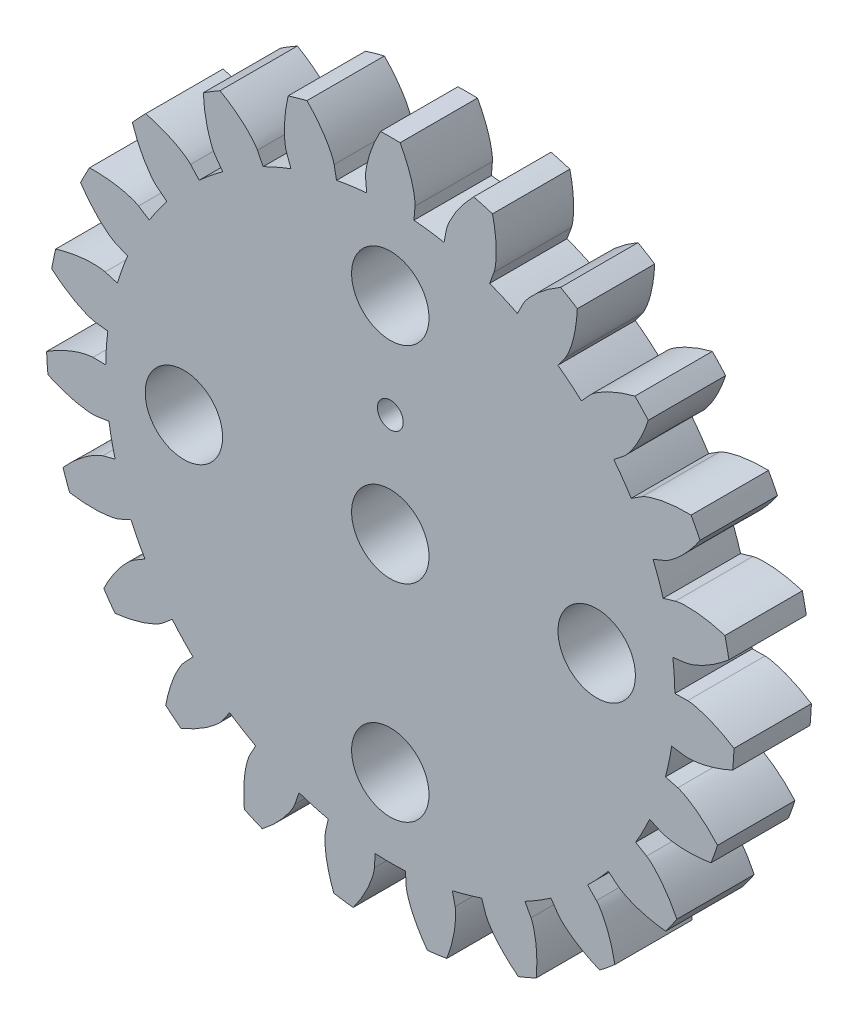
from build123d import *

# Parameters (mm, degrees)
BOSS_EXTRUDE1_DEPTH = 3
SKETCH2_R           = 1.5
SKETCH2_R_2         = 0.5
CUT_EXTRUDE1_DEPTH  = 4.0000001


with BuildPart() as part:
    # Model → Boss-Extrude1 (new body)
    with BuildSketch(Plane.XY):
        with BuildLine():
            Line((-3.538746102, -10.448013917), (-3.69731571, -10.916184682))
            add(Edge.make_bspline(
                [(-3.69731571, -10.916184682), (-3.706904602, -10.940308677), (-3.747498158, -11.035961617), (-3.865200891, -11.238603118), (-4.093466254, -11.554754655), (-4.463378416, -11.956665333), (-4.776092769, -12.231743922), (-4.961450629, -12.373903165)],
                knots=[34.58462916, 34.58462916, 34.58462916, 34.58462916, 34.662508722, 34.896108405, 35.285436008, 35.830492648, 36.531278694, 36.531278694, 36.531278694, 36.531278694], degree=3))
            ThreePointArc((-4.961450629, -12.373903165), (-5.31129279, -12.227822405), (-5.656839729, -12.071853054))
            add(Edge.make_bspline(
                [(-5.656839729, -12.071853054), (-5.679461232, -11.839355625), (-5.691868071, -11.423056974), (-5.650622002, -10.878386466), (-5.57537033, -10.495771704), (-5.507611003, -10.271436721), (-5.465411654, -10.176481275), (-5.454325899, -10.153007459)],
                knots=[37.289536731, 37.289536731, 37.289536731, 37.289536731, 37.990322777, 38.535379417, 38.92470702, 39.158306703, 39.236186265, 39.236186265, 39.236186265, 39.236186265], degree=3))
            Line((-5.454325899, -10.153007459), (-5.220402051, -9.717567659))
            ThreePointArc((-5.220402051, -9.717567659), (-5.731548399, -9.425129799), (-6.226360217, -9.105830947))
            Line((-6.226360217, -9.105830947), (-6.505360594, -9.513859102))
            add(Edge.make_bspline(
                [(-6.505360594, -9.513859102), (-6.521102481, -9.534501462), (-6.585997572, -9.615655321), (-6.75400759, -9.779026508), (-7.059104919, -10.02186903), (-7.523733938, -10.309074663), (-7.899067309, -10.489583269), (-8.115905702, -10.576461909)],
                knots=[41.402695863, 41.402695863, 41.402695863, 41.402695863, 41.480575425, 41.714175107, 42.103502711, 42.64855935, 43.349345397, 43.349345397, 43.349345397, 43.349345397], degree=3))
            ThreePointArc((-8.115905702, -10.576461909), (-8.413362649, -10.341411935), (-8.704015743, -10.097998902))
            add(Edge.make_bspline(
                [(-8.704015743, -10.097998902), (-8.663071323, -9.8680199), (-8.562702051, -9.463811408), (-8.376035154, -8.950466815), (-8.200345791, -8.602343105), (-8.074574309, -8.404608319), (-8.008321154, -8.324559327), (-7.991313329, -8.304946884)],
                knots=[44.107603434, 44.107603434, 44.107603434, 44.107603434, 44.80838948, 45.35344612, 45.742773723, 45.976373406, 46.054252968, 46.054252968, 46.054252968, 46.054252968], degree=3))
            Line((-7.991313329, -8.304946884), (-7.64858376, -7.948766272))
            ThreePointArc((-7.64858376, -7.948766272), (-8.061876625, -7.529267167), (-8.452193678, -7.088310152))
            Line((-8.452193678, -7.088310152), (-8.830932644, -7.405934115))
            add(Edge.make_bspline(
                [(-8.830932644, -7.405934115), (-8.85166002, -7.42156389), (-8.936043675, -7.482199858), (-9.141900445, -7.594184238), (-9.501202065, -7.745707227), (-10.026088532, -7.896907086), (-10.436204162, -7.969458212), (-10.668441176, -7.994612858)],
                knots=[48.220762566, 48.220762566, 48.220762566, 48.220762566, 48.298642127, 48.53224181, 48.921569414, 49.466626053, 50.167412099, 50.167412099, 50.167412099, 50.167412099], degree=3))
            ThreePointArc((-10.668441176, -7.994612858), (-10.891451889, -7.688026251), (-11.105654727, -7.375222367))
            add(Edge.make_bspline(
                [(-11.105654727, -7.375222367), (-11.004181046, -7.164818282), (-10.798479592, -6.802678243), (-10.480236096, -6.358731987), (-10.217139118, -6.070918071), (-10.042683378, -5.914448566), (-9.957290109, -5.855242896), (-9.935621607, -5.840946392)],
                knots=[50.925670137, 50.925670137, 50.925670137, 50.925670137, 51.626456183, 52.171512822, 52.560840426, 52.794440109, 52.872319671, 52.872319671, 52.872319671, 52.872319671], degree=3))
            Line((-9.935621607, -5.840946392), (-9.509505001, -5.590441255))
            ThreePointArc((-9.509505001, -5.590441255), (-9.794292341, -5.074993233), (-10.051166601, -4.54508182))
            Line((-10.051166601, -4.54508182), (-10.501554817, -4.748744875))
            add(Edge.make_bspline(
                [(-10.501554817, -4.748744875), (-10.52573043, -4.758202876), (-10.623344298, -4.79382386), (-10.851780364, -4.846116064), (-11.238638519, -4.895081752), (-11.784854006, -4.899062036), (-12.199335495, -4.858274897), (-12.429747173, -4.819839944)],
                knots=[55.038829268, 55.038829268, 55.038829268, 55.038829268, 55.11670883, 55.350308513, 55.739636117, 56.284692756, 56.985478802, 56.985478802, 56.985478802, 56.985478802], degree=3))
            ThreePointArc((-12.429747173, -4.819839944), (-12.561771967, -4.46445483), (-12.683638105, -4.105459328))
            add(Edge.make_bspline(
                [(-12.683638105, -4.105459328), (-12.529161, -3.930234869), (-12.233383301, -3.637021553), (-11.807165871, -3.295399096), (-11.476173977, -3.089240816), (-11.265972562, -2.98564122), (-11.167772409, -2.951669885), (-11.143050283, -2.943749626)],
                knots=[57.74373684, 57.74373684, 57.74373684, 57.74373684, 58.444522886, 58.989579525, 59.378907129, 59.612506812, 59.690386373, 59.690386373, 59.690386373, 59.690386373], degree=3))
            Line((-11.143050283, -2.943749626), (-10.665149759, -2.817498783))
            ThreePointArc((-10.665149759, -2.817498783), (-10.800310201, -2.244330268), (-10.904690477, -1.664765561))
            Line((-10.904690477, -1.664765561), (-11.393324712, -1.739362951))
            add(Edge.make_bspline(
                [(-11.393324712, -1.739362951), (-11.419155565, -1.741947722), (-11.522760073, -1.749911877), (-11.756833378, -1.738633631), (-12.142556567, -1.681410458), (-12.66959077, -1.537875967), (-13.057697923, -1.386775558), (-13.269195685, -1.287601551)],
                knots=[61.856895971, 61.856895971, 61.856895971, 61.856895971, 61.934775533, 62.168375216, 62.557702819, 63.102759459, 63.803545505, 63.803545505, 63.803545505, 63.803545505], degree=3))
            ThreePointArc((-13.269195685, -1.287601551), (-13.300442885, -0.909775217), (-13.320934069, -0.531213152))
            add(Edge.make_bspline(
                [(-13.320934069, -0.531213152), (-13.124910401, -0.404163916), (-12.760992935, -0.201623613), (-12.258412168, 0.012338471), (-11.884073513, 0.121551298), (-11.6537161, 0.164597476), (-11.549992118, 0.170814978), (-11.524049895, 0.171771583)],
                knots=[64.561803542, 64.561803542, 64.561803542, 64.561803542, 65.262589589, 65.807646228, 66.196973832, 66.430573514, 66.508453076, 66.508453076, 66.508453076, 66.508453076], degree=3))
            Line((-11.524049895, 0.171771583), (-11.02980915, 0.164404683))
            ThreePointArc((-11.02980915, 0.164404683), (-11.005318461, 0.752784406), (-10.949463347, 1.339018743))
            Line((-10.949463347, 1.339018743), (-11.440103834, 1.399019565))
            add(Edge.make_bspline(
                [(-11.440103834, 1.399019565), (-11.465674172, 1.403499726), (-11.567585446, 1.423783064), (-11.789935844, 1.497795305), (-12.145916744, 1.656963359), (-12.614681946, 1.937367327), (-12.947630631, 2.18757458), (-13.124528655, 2.340132359)],
                knots=[68.674962674, 68.674962674, 68.674962674, 68.674962674, 68.752842236, 68.986441919, 69.375769522, 69.920826162, 70.621612208, 70.621612208, 70.621612208, 70.621612208], degree=3))
            ThreePointArc((-13.124528655, 2.340132359), (-13.052680799, 2.712378261), (-12.970277292, 3.082430673))
            add(Edge.make_bspline(
                [(-12.970277292, 3.082430673), (-12.747245239, 3.151882026), (-12.342178101, 3.248727828), (-11.800508112, 3.319160949), (-11.410585682, 3.323328508), (-11.177156827, 3.302628731), (-11.07560175, 3.280631276), (-11.050363446, 3.274553279)],
                knots=[71.379870245, 71.379870245, 71.379870245, 71.379870245, 72.080656291, 72.625712931, 73.015040534, 73.248640217, 73.326519779, 73.326519779, 73.326519779, 73.326519779], degree=3))
            Line((-11.050363446, 3.274553279), (-10.576438054, 3.134115007))
            ThreePointArc((-10.576438054, 3.134115007), (-10.394112597, 3.694068504), (-10.182164611, 4.243494152))
            Line((-10.182164611, 4.243494152), (-10.638422789, 4.433643201))
            add(Edge.make_bspline(
                [(-10.638422789, 4.433643201), (-10.661836177, 4.444856019), (-10.754495925, 4.49188253), (-10.948632704, 4.623139615), (-11.248469839, 4.872447783), (-11.624199871, 5.268924949), (-11.877296806, 5.599682319), (-12.006475376, 5.794309358)],
                knots=[75.493029377, 75.493029377, 75.493029377, 75.493029377, 75.570908939, 75.804508621, 76.193836225, 76.738892864, 77.439678911, 77.439678911, 77.439678911, 77.439678911], degree=3))
            ThreePointArc((-12.006475376, 5.794309358), (-11.836861091, 6.133367052), (-11.657674383, 6.467464716))
            add(Edge.make_bspline(
                [(-11.657674383, 6.467464716), (-11.424175213, 6.474167298), (-11.008000378, 6.458135988), (-10.467414354, 6.379816444), (-10.090826911, 6.278629646), (-9.871638964, 6.195719121), (-9.779784667, 6.147138159), (-9.757122092, 6.134476338)],
                knots=[78.197936948, 78.197936948, 78.197936948, 78.197936948, 78.898722994, 79.443779633, 79.833107237, 80.06670692, 80.144586482, 80.144586482, 80.144586482, 80.144586482], degree=3))
            Line((-9.757122092, 6.134476338), (-9.338660931, 5.871382358))
            ThreePointArc((-9.338660931, 5.871382358), (-9.012022951, 6.361380441), (-8.659701306, 6.833249014))
            Line((-8.659701306, 6.833249014), (-9.047738594, 7.139443803))
            add(Edge.make_bspline(
                [(-9.047738594, 7.139443803), (-9.067258567, 7.156557676), (-9.14379464, 7.226839617), (-9.295319562, 7.405606809), (-9.516775385, 7.726565045), (-9.771604069, 8.209710512), (-9.926078213, 8.596487237), (-9.997956744, 8.818748938)],
                knots=[82.31109608, 82.31109608, 82.31109608, 82.31109608, 82.388975641, 82.622575324, 83.011902928, 83.556959567, 84.257745613, 84.257745613, 84.257745613, 84.257745613], degree=3))
            ThreePointArc((-9.997956744, 8.818748938), (-9.743155546, 9.099472067), (-9.480475096, 9.372836489))
            add(Edge.make_bspline(
                [(-9.480475096, 9.372836489), (-9.253826374, 9.316293198), (-8.857409626, 9.188573746), (-8.358000358, 8.967310139), (-8.02267767, 8.768273546), (-7.833986799, 8.629301368), (-7.758645695, 8.557739927), (-7.740239628, 8.539433351)],
                knots=[85.016003651, 85.016003651, 85.016003651, 85.016003651, 85.716789697, 86.261846336, 86.65117394, 86.884773623, 86.962653185, 86.962653185, 86.962653185, 86.962653185], degree=3))
            Line((-7.740239628, 8.539433351), (-7.408278049, 8.173196139))
            ThreePointArc((-7.408278049, 8.173196139), (-6.96155279, 8.556897892), (-6.49498757, 8.916213055))
            Line((-6.49498757, 8.916213055), (-6.786025017, 9.315744518))
            add(Edge.make_bspline(
                [(-6.786025017, 9.315744518), (-6.800203869, 9.337490189), (-6.854939937, 9.42581507), (-6.952615092, 9.638834025), (-7.079265237, 10.007638324), (-7.194293095, 10.541619403), (-7.238687807, 10.955730023), (-7.247935398, 11.189142253)],
                knots=[89.129162782, 89.129162782, 89.129162782, 89.129162782, 89.207042344, 89.440642027, 89.829969631, 90.37502627, 91.075812316, 91.075812316, 91.075812316, 91.075812316], degree=3))
            ThreePointArc((-7.247935398, 11.189142253), (-6.926844725, 11.390710866), (-6.600152341, 11.583067856))
            add(Edge.make_bspline(
                [(-6.600152341, 11.583067856), (-6.397163565, 11.467472251), (-6.049905322, 11.237537024), (-5.628711711, 10.889739464), (-5.359523128, 10.607614709), (-5.215323671, 10.422887809), (-5.162083466, 10.333653274), (-5.149299001, 10.311059658)],
                knots=[91.834070354, 91.834070354, 91.834070354, 91.834070354, 92.5348564, 93.079913039, 93.469240643, 93.702840326, 93.780719887, 93.780719887, 93.780719887, 93.780719887], degree=3))
            Line((-5.149299001, 10.311059658), (-4.928457074, 9.868841353))
            ThreePointArc((-4.928457074, 9.868841353), (-4.394776106, 10.117789371), (-3.848570319, 10.337902364))
            Line((-3.848570319, 10.337902364), (-4.02102301, 10.80113908))
            add(Edge.make_bspline(
                [(-4.02102301, 10.80113908), (-4.02880916, 10.82590377), (-4.057685698, 10.925720939), (-4.094266967, 11.157193015), (-4.116718371, 11.546490851), (-4.083414314, 12.091704607), (-4.014437041, 12.502436432), (-3.96036784, 12.729688074)],
                knots=[95.947229485, 95.947229485, 95.947229485, 95.947229485, 96.025109047, 96.25870873, 96.648036333, 97.193092973, 97.893879019, 97.893879019, 97.893879019, 97.893879019], degree=3))
            ThreePointArc((-3.96036784, 12.729688074), (-3.59680152, 12.837152749), (-3.23032648, 12.93423607))
            add(Edge.make_bspline(
                [(-3.23032648, 12.93423607), (-3.066052401, 12.768161347), (-2.793707216, 12.453063589), (-2.481967266, 12.00452663), (-2.298877274, 11.660237616), (-2.209863845, 11.443456342), (-2.18267312, 11.34316683), (-2.176458423, 11.31796184)],
                knots=[98.652137056, 98.652137056, 98.652137056, 98.652137056, 99.352923103, 99.897979742, 100.287307346, 100.520907028, 100.59878659, 100.59878659, 100.59878659, 100.59878659], degree=3))
            Line((-2.176458423, 11.31796184), (-2.083114985, 10.83255975))
            ThreePointArc((-2.083114985, 10.83255975), (-1.502058983, 10.928290699), (-0.916722213, 10.992876747))
            Line((-0.916722213, 10.992876747), (-0.95780012, 11.485462568))
            add(Edge.make_bspline(
                [(-0.95780012, 11.485462568), (-0.958616105, 11.511409594), (-0.959491473, 11.615316069), (-0.932265791, 11.848074041), (-0.848853337, 12.228992973), (-0.669687373, 12.745003397), (-0.492453845, 13.121894326), (-0.379077917, 13.326131165)],
                knots=[102.765296188, 102.765296188, 102.765296188, 102.765296188, 102.84317575, 103.076775433, 103.466103036, 104.011159676, 104.711945722, 104.711945722, 104.711945722, 104.711945722], degree=3))
            ThreePointArc((-0.379077917, 13.326131165), (0, 13.331521739), (0.379077917, 13.326131165))
            add(Edge.make_bspline(
                [(0.379077917, 13.326131165), (0.492453845, 13.121894326), (0.669687373, 12.745003397), (0.848853337, 12.228992973), (0.932265791, 11.848074041), (0.959491473, 11.615316069), (0.958616105, 11.511409594), (0.95780012, 11.485462568)],
                knots=[105.470203759, 105.470203759, 105.470203759, 105.470203759, 106.170989805, 106.716046445, 107.105374048, 107.338973731, 107.416853293, 107.416853293, 107.416853293, 107.416853293], degree=3))
            Line((0.95780012, 11.485462568), (0.916722213, 10.992876747))
            ThreePointArc((0.916722213, 10.992876747), (1.502058983, 10.928290699), (2.083114985, 10.83255975))
            Line((2.083114985, 10.83255975), (2.176458423, 11.31796184))
            add(Edge.make_bspline(
                [(2.176458423, 11.31796184), (2.18267312, 11.34316683), (2.209863845, 11.443456342), (2.298877274, 11.660237616), (2.481967266, 12.00452663), (2.793707216, 12.453063589), (3.066052401, 12.768161347), (3.23032648, 12.93423607)],
                knots=[109.583362891, 109.583362891, 109.583362891, 109.583362891, 109.661242453, 109.894842135, 110.284169739, 110.829226378, 111.530012424, 111.530012424, 111.530012424, 111.530012424], degree=3))
            ThreePointArc((3.23032648, 12.93423607), (3.59680152, 12.837152749), (3.96036784, 12.729688074))
            add(Edge.make_bspline(
                [(3.96036784, 12.729688074), (4.014437041, 12.502436432), (4.083414314, 12.091704607), (4.116718371, 11.546490851), (4.094266967, 11.157193015), (4.057685698, 10.925720939), (4.02880916, 10.82590377), (4.02102301, 10.80113908)],
                knots=[112.288270462, 112.288270462, 112.288270462, 112.288270462, 112.989056508, 113.534113147, 113.923440751, 114.157040434, 114.234919996, 114.234919996, 114.234919996, 114.234919996], degree=3))
            Line((4.02102301, 10.80113908), (3.848570319, 10.337902364))
            ThreePointArc((3.848570319, 10.337902364), (4.394776106, 10.117789371), (4.928457074, 9.868841353))
            Line((4.928457074, 9.868841353), (5.149299001, 10.311059658))
            add(Edge.make_bspline(
                [(5.149299001, 10.311059658), (5.162083466, 10.333653274), (5.215323671, 10.422887809), (5.359523128, 10.607614709), (5.628711711, 10.889739464), (6.049905322, 11.237537024), (6.397163565, 11.467472251), (6.600152341, 11.583067856)],
                knots=[116.401429594, 116.401429594, 116.401429594, 116.401429594, 116.479309155, 116.712908838, 117.102236442, 117.647293081, 118.348079127, 118.348079127, 118.348079127, 118.348079127], degree=3))
            ThreePointArc((6.600152341, 11.583067856), (6.926844725, 11.390710866), (7.247935398, 11.189142253))
            add(Edge.make_bspline(
                [(7.247935398, 11.189142253), (7.238687807, 10.955730023), (7.194293095, 10.541619403), (7.079265237, 10.007638324), (6.952615092, 9.638834025), (6.854939937, 9.42581507), (6.800203869, 9.337490189), (6.786025017, 9.315744518)],
                knots=[119.106337165, 119.106337165, 119.106337165, 119.106337165, 119.807123211, 120.35217985, 120.741507454, 120.975107137, 121.052986698, 121.052986698, 121.052986698, 121.052986698], degree=3))
            Line((6.786025017, 9.315744518), (6.49498757, 8.916213055))
            ThreePointArc((6.49498757, 8.916213055), (6.96155279, 8.556897892), (7.408278049, 8.173196139))
            Line((7.408278049, 8.173196139), (7.740239628, 8.539433351))
            add(Edge.make_bspline(
                [(7.740239628, 8.539433351), (7.758645695, 8.557739927), (7.833986799, 8.629301368), (8.02267767, 8.768273546), (8.358000358, 8.967310139), (8.857409626, 9.188573746), (9.253826374, 9.316293198), (9.480475096, 9.372836489)],
                knots=[123.219496296, 123.219496296, 123.219496296, 123.219496296, 123.297375858, 123.530975541, 123.920303145, 124.465359784, 125.16614583, 125.16614583, 125.16614583, 125.16614583], degree=3))
            ThreePointArc((9.480475096, 9.372836489), (9.743155546, 9.099472067), (9.997956744, 8.818748938))
            add(Edge.make_bspline(
                [(9.997956744, 8.818748938), (9.926078213, 8.596487237), (9.771604069, 8.209710512), (9.516775385, 7.726565045), (9.295319562, 7.405606809), (9.14379464, 7.226839617), (9.067258567, 7.156557676), (9.047738594, 7.139443803)],
                knots=[125.924403868, 125.924403868, 125.924403868, 125.924403868, 126.625189914, 127.170246553, 127.559574157, 127.79317384, 127.871053401, 127.871053401, 127.871053401, 127.871053401], degree=3))
            Line((9.047738594, 7.139443803), (8.659701306, 6.833249014))
            ThreePointArc((8.659701306, 6.833249014), (9.012022951, 6.361380441), (9.338660931, 5.871382358))
            Line((9.338660931, 5.871382358), (9.757122092, 6.134476338))
            add(Edge.make_bspline(
                [(9.757122092, 6.134476338), (9.779784667, 6.147138159), (9.871638964, 6.195719121), (10.090826911, 6.278629646), (10.467414354, 6.379816444), (11.008000378, 6.458135988), (11.424175213, 6.474167298), (11.657674383, 6.467464716)],
                knots=[130.037562999, 130.037562999, 130.037562999, 130.037562999, 130.115442561, 130.349042244, 130.738369847, 131.283426487, 131.984212533, 131.984212533, 131.984212533, 131.984212533], degree=3))
            ThreePointArc((11.657674383, 6.467464716), (11.836861091, 6.133367052), (12.006475376, 5.794309358))
            add(Edge.make_bspline(
                [(12.006475376, 5.794309358), (11.877296806, 5.599682319), (11.624199871, 5.268924949), (11.248469839, 4.872447783), (10.948632704, 4.623139615), (10.754495925, 4.49188253), (10.661836177, 4.444856019), (10.638422789, 4.433643201)],
                knots=[132.74247057, 132.74247057, 132.74247057, 132.74247057, 133.443256617, 133.988313256, 134.37764086, 134.611240542, 134.689120104, 134.689120104, 134.689120104, 134.689120104], degree=3))
            Line((10.638422789, 4.433643201), (10.182164611, 4.243494152))
            ThreePointArc((10.182164611, 4.243494152), (10.394112597, 3.694068504), (10.576438054, 3.134115007))
            Line((10.576438054, 3.134115007), (11.050363446, 3.274553279))
            add(Edge.make_bspline(
                [(11.050363446, 3.274553279), (11.07560175, 3.280631276), (11.177156827, 3.302628731), (11.410585682, 3.323328508), (11.800508112, 3.319160949), (12.342178101, 3.248727828), (12.747245239, 3.151882026), (12.970277292, 3.082430673)],
                knots=[136.855629702, 136.855629702, 136.855629702, 136.855629702, 136.933509264, 137.167108946, 137.55643655, 138.101493189, 138.802279236, 138.802279236, 138.802279236, 138.802279236], degree=3))
            ThreePointArc((12.970277292, 3.082430673), (13.052680799, 2.712378261), (13.124528655, 2.340132359))
            add(Edge.make_bspline(
                [(13.124528655, 2.340132359), (12.947630631, 2.18757458), (12.614681946, 1.937367327), (12.145916744, 1.656963359), (11.789935844, 1.497795305), (11.567585446, 1.423783064), (11.465674172, 1.403499726), (11.440103834, 1.399019565)],
                knots=[139.560537273, 139.560537273, 139.560537273, 139.560537273, 140.261323319, 140.806379959, 141.195707562, 141.429307245, 141.507186807, 141.507186807, 141.507186807, 141.507186807], degree=3))
            Line((11.440103834, 1.399019565), (10.949463347, 1.339018743))
            ThreePointArc((10.949463347, 1.339018743), (11.005318461, 0.752784406), (11.02980915, 0.164404683))
            Line((11.02980915, 0.164404683), (11.524049895, 0.171771583))
            add(Edge.make_bspline(
                [(11.524049895, 0.171771583), (11.549992118, 0.170814978), (11.6537161, 0.164597476), (11.884073513, 0.121551298), (12.258412168, 0.012338471), (12.760992935, -0.201623613), (13.124910401, -0.404163916), (13.320934069, -0.531213152)],
                knots=[143.673696405, 143.673696405, 143.673696405, 143.673696405, 143.751575967, 143.985175649, 144.374503253, 144.919559892, 145.620345938, 145.620345938, 145.620345938, 145.620345938], degree=3))
            ThreePointArc((13.320934069, -0.531213152), (13.300442885, -0.909775217), (13.269195685, -1.287601551))
            add(Edge.make_bspline(
                [(13.269195685, -1.287601551), (13.057697923, -1.386775558), (12.66959077, -1.537875967), (12.142556567, -1.681410458), (11.756833378, -1.738633631), (11.522760073, -1.749911877), (11.419155565, -1.741947722), (11.393324712, -1.739362951)],
                knots=[146.378603976, 146.378603976, 146.378603976, 146.378603976, 147.079390022, 147.624446661, 148.013774265, 148.247373948, 148.32525351, 148.32525351, 148.32525351, 148.32525351], degree=3))
            Line((11.393324712, -1.739362951), (10.904690477, -1.664765561))
            ThreePointArc((10.904690477, -1.664765561), (10.800310201, -2.244330268), (10.665149759, -2.817498783))
            Line((10.665149759, -2.817498783), (11.143050283, -2.943749626))
            add(Edge.make_bspline(
                [(11.143050283, -2.943749626), (11.167772409, -2.951669885), (11.265972562, -2.98564122), (11.476173977, -3.089240816), (11.807165871, -3.295399096), (12.233383301, -3.637021553), (12.529161, -3.930234869), (12.683638105, -4.105459328)],
                knots=[150.491763108, 150.491763108, 150.491763108, 150.491763108, 150.569642669, 150.803242352, 151.192569956, 151.737626595, 152.438412641, 152.438412641, 152.438412641, 152.438412641], degree=3))
            ThreePointArc((12.683638105, -4.105459328), (12.561771967, -4.46445483), (12.429747173, -4.819839944))
            add(Edge.make_bspline(
                [(12.429747173, -4.819839944), (12.199335495, -4.858274897), (11.784854006, -4.899062036), (11.238638519, -4.895081752), (10.851780364, -4.846116064), (10.623344298, -4.79382386), (10.52573043, -4.758202876), (10.501554817, -4.748744875)],
                knots=[153.196670679, 153.196670679, 153.196670679, 153.196670679, 153.897456725, 154.442513364, 154.831840968, 155.065440651, 155.143320212, 155.143320212, 155.143320212, 155.143320212], degree=3))
            Line((10.501554817, -4.748744875), (10.051166601, -4.54508182))
            ThreePointArc((10.051166601, -4.54508182), (9.794292341, -5.074993233), (9.509505001, -5.590441255))
            Line((9.509505001, -5.590441255), (9.935621607, -5.840946392))
            add(Edge.make_bspline(
                [(9.935621607, -5.840946392), (9.957290109, -5.855242896), (10.042683378, -5.914448566), (10.217139118, -6.070918071), (10.480236096, -6.358731987), (10.798479592, -6.802678243), (11.004181046, -7.164818282), (11.105654727, -7.375222367)],
                knots=[157.30982981, 157.30982981, 157.30982981, 157.30982981, 157.387709372, 157.621309055, 158.010636659, 158.555693298, 159.256479344, 159.256479344, 159.256479344, 159.256479344], degree=3))
            ThreePointArc((11.105654727, -7.375222367), (10.891451889, -7.688026251), (10.668441176, -7.994612858))
            add(Edge.make_bspline(
                [(10.668441176, -7.994612858), (10.436204162, -7.969458212), (10.026088532, -7.896907086), (9.501202065, -7.745707227), (9.141900445, -7.594184238), (8.936043675, -7.482199858), (8.85166002, -7.42156389), (8.830932644, -7.405934115)],
                knots=[160.014737382, 160.014737382, 160.014737382, 160.014737382, 160.715523428, 161.260580067, 161.649907671, 161.883507354, 161.961386915, 161.961386915, 161.961386915, 161.961386915], degree=3))
            Line((8.830932644, -7.405934115), (8.452193678, -7.088310152))
            ThreePointArc((8.452193678, -7.088310152), (8.061876625, -7.529267167), (7.64858376, -7.948766272))
            Line((7.64858376, -7.948766272), (7.991313329, -8.304946884))
            add(Edge.make_bspline(
                [(7.991313329, -8.304946884), (8.008321154, -8.324559327), (8.074574309, -8.404608319), (8.200345791, -8.602343105), (8.376035154, -8.950466815), (8.562702051, -9.463811408), (8.663071323, -9.8680199), (8.704015743, -10.097998902)],
                knots=[164.127896513, 164.127896513, 164.127896513, 164.127896513, 164.205776075, 164.439375758, 164.828703361, 165.373760001, 166.074546047, 166.074546047, 166.074546047, 166.074546047], degree=3))
            ThreePointArc((8.704015743, -10.097998902), (8.413362649, -10.341411935), (8.115905702, -10.576461909))
            add(Edge.make_bspline(
                [(8.115905702, -10.576461909), (7.899067309, -10.489583269), (7.523733938, -10.309074663), (7.059104919, -10.02186903), (6.75400759, -9.779026508), (6.585997572, -9.615655321), (6.521102481, -9.534501462), (6.505360594, -9.513859102)],
                knots=[166.832804084, 166.832804084, 166.832804084, 166.832804084, 167.533590131, 168.07864677, 168.467974374, 168.701574056, 168.779453618, 168.779453618, 168.779453618, 168.779453618], degree=3))
            Line((6.505360594, -9.513859102), (6.226360217, -9.105830947))
            ThreePointArc((6.226360217, -9.105830947), (5.731548399, -9.425129799), (5.220402051, -9.717567659))
            Line((5.220402051, -9.717567659), (5.454325899, -10.153007459))
            add(Edge.make_bspline(
                [(5.454325899, -10.153007459), (5.465411654, -10.176481275), (5.507611003, -10.271436721), (5.57537033, -10.495771704), (5.650622002, -10.878386466), (5.691868071, -11.423056974), (5.679461232, -11.839355625), (5.656839729, -12.071853054)],
                knots=[170.945963216, 170.945963216, 170.945963216, 170.945963216, 171.023842778, 171.25744246, 171.646770064, 172.191826703, 172.89261275, 172.89261275, 172.89261275, 172.89261275], degree=3))
            ThreePointArc((5.656839729, -12.071853054), (5.31129279, -12.227822405), (4.961450629, -12.373903165))
            add(Edge.make_bspline(
                [(4.961450629, -12.373903165), (4.776092769, -12.231743922), (4.463378416, -11.956665333), (4.093466254, -11.554754655), (3.865200891, -11.238603118), (3.747498158, -11.035961617), (3.706904602, -10.940308677), (3.69731571, -10.916184682)],
                knots=[173.650870787, 173.650870787, 173.650870787, 173.650870787, 174.351656833, 174.896713473, 175.286041076, 175.519640759, 175.597520321, 175.597520321, 175.597520321, 175.597520321], degree=3))
            Line((3.69731571, -10.916184682), (3.538746102, -10.448013917))
            ThreePointArc((3.538746102, -10.448013917), (2.97613745, -10.621973671), (2.405047004, -10.765661507))
            Line((2.405047004, -10.765661507), (2.512816069, -11.248065917))
            add(Edge.make_bspline(
                [(2.512816069, -11.248065917), (2.517157574, -11.273660161), (2.532173385, -11.37647965), (2.536895158, -11.610776931), (2.506128066, -11.999505958), (2.398894274, -12.535106662), (2.274631483, -12.932620505), (2.190121791, -13.15039309)],
                knots=[177.764029919, 177.764029919, 177.764029919, 177.764029919, 177.841909481, 178.075509163, 178.464836767, 179.009893406, 179.710679452, 179.710679452, 179.710679452, 179.710679452], degree=3))
            ThreePointArc((2.190121791, -13.15039309), (1.815308643, -13.207351226), (1.439027461, -13.253628629))
            add(Edge.make_bspline(
                [(1.439027461, -13.253628629), (1.298897277, -13.066732084), (1.071994537, -12.717484833), (0.824233924, -12.230676987), (0.689729923, -11.864663948), (0.63106395, -11.637781127), (0.617782568, -11.534723247), (0.615057833, -11.508906783)],
                knots=[180.46893749, 180.46893749, 180.46893749, 180.46893749, 181.169723536, 181.714780175, 182.104107779, 182.337707462, 182.415587024, 182.415587024, 182.415587024, 182.415587024], degree=3))
            Line((0.615057833, -11.508906783), (0.588679377, -11.015315491))
            ThreePointArc((0.588679377, -11.015315491), (0, -11.031034348), (-0.588679377, -11.015315491))
            Line((-0.588679377, -11.015315491), (-0.615057833, -11.508906783))
            add(Edge.make_bspline(
                [(-0.615057833, -11.508906783), (-0.617782568, -11.534723247), (-0.63106395, -11.637781127), (-0.689729923, -11.864663948), (-0.824233924, -12.230676987), (-1.071994537, -12.717484833), (-1.298897277, -13.066732084), (-1.439027461, -13.253628629)],
                knots=[184.582096622, 184.582096622, 184.582096622, 184.582096622, 184.659976183, 184.893575866, 185.28290347, 185.827960109, 186.528746155, 186.528746155, 186.528746155, 186.528746155], degree=3))
            ThreePointArc((-1.439027461, -13.253628629), (-1.815308643, -13.207351226), (-2.190121791, -13.15039309))
            add(Edge.make_bspline(
                [(-2.190121791, -13.15039309), (-2.274631483, -12.932620505), (-2.398894274, -12.535106662), (-2.506128066, -11.999505958), (-2.536895158, -11.610776931), (-2.532173385, -11.37647965), (-2.517157574, -11.273660161), (-2.512816069, -11.248065917)],
                knots=[187.287004193, 187.287004193, 187.287004193, 187.287004193, 187.987790239, 188.532846878, 188.922174482, 189.155774165, 189.233653726, 189.233653726, 189.233653726, 189.233653726], degree=3))
            Line((-2.512816069, -11.248065917), (-2.405047004, -10.765661507))
            ThreePointArc((-2.405047004, -10.765661507), (-2.97613745, -10.621973671), (-3.538746102, -10.448013917))
        make_face()
    extrude(amount=BOSS_EXTRUDE1_DEPTH)

    # Sketch2 → Cut-Extrude1 (cut, through all)
    with BuildSketch(Plane.XY):
        Circle(SKETCH2_R)
        with Locations((0, 8)):
            Circle(SKETCH2_R)
        with Locations((-8, 0)):
            Circle(SKETCH2_R)
        with Locations((0, -8)):
            Circle(SKETCH2_R)
        with Locations((8, 0)):
            Circle(SKETCH2_R)
        with Locations((0, 4)):
            Circle(SKETCH2_R_2)
    extrude(amount=CUT_EXTRUDE1_DEPTH, mode=Mode.SUBTRACT)


solid = part.part
